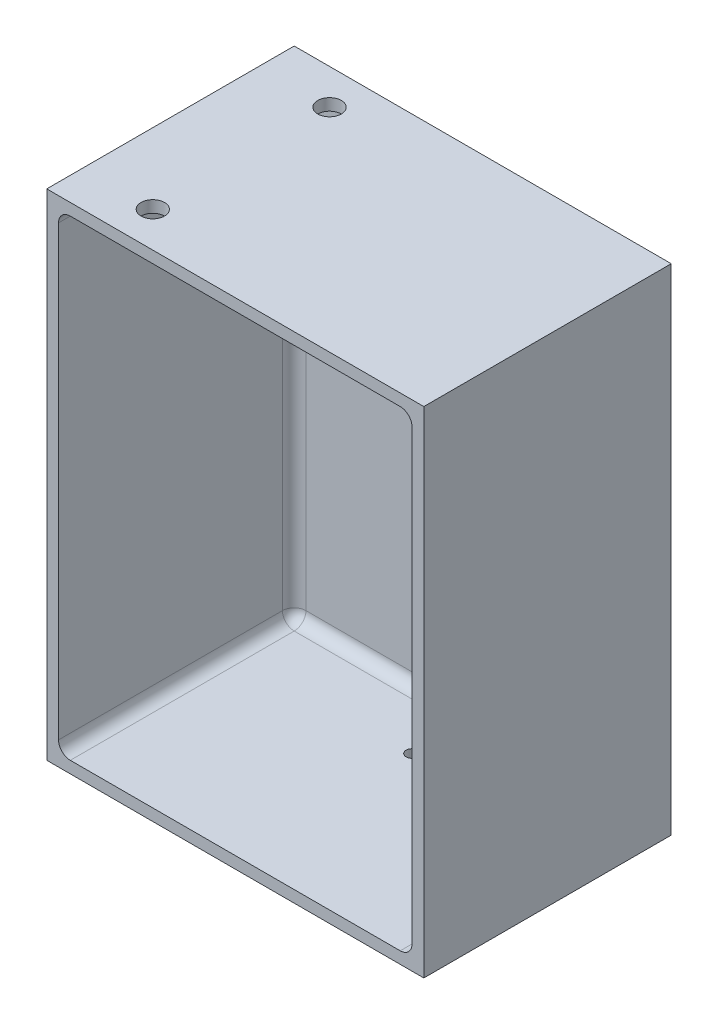
from build123d import *

# Parameters (mm, degrees)
SKETCH1_W           = 160
SKETCH1_H           = 210
SKETCH1_W_2         = 150
SKETCH1_H_2         = 200
BOSS_EXTRUDE1_DEPTH = 100
SKETCH3_W           = 160
SKETCH3_H           = 210
BOSS_EXTRUDE2_DEPTH = 5
FILLET1_R           = 5
SKETCH4_R           = 5
CUT_EXTRUDE1_DEPTH  = 48
SKETCH5_R           = 2.5
CUT_EXTRUDE2_DEPTH  = 40


with BuildPart() as part:
    # Sketch1 → Boss-Extrude1 (new body)
    with BuildSketch(Plane.XY):
        Rectangle(SKETCH1_W, SKETCH1_H)
        Rectangle(SKETCH1_W_2, SKETCH1_H_2, mode=Mode.SUBTRACT)
    extrude(amount=BOSS_EXTRUDE1_DEPTH)

    # Sketch3 → Boss-Extrude2 (add)
    with BuildSketch(Plane(origin=(0, 0, 0), x_dir=(-1, 0, 0), z_dir=(0, 0, -1))):
        Rectangle(SKETCH3_W, SKETCH3_H)
    extrude(amount=BOSS_EXTRUDE2_DEPTH)

    # Fillet1
    fillet1_edges = [part.edges().sort_by_distance(p)[0] for p in [
        (-75, 0, 0),
        (-75, 100, 50),
        (0, -100, 0),
        (-75, -100, 50),
        (75, 0, 0),
        (75, -100, 50),
        (0, 100, 0),
        (75, 100, 50),
    ]]
    fillet(fillet1_edges, radius=FILLET1_R)

    # Sketch4 → Cut-Extrude1 (cut)
    with BuildSketch(Plane(origin=(0, 105, 0), x_dir=(1, 0, 0), z_dir=(0, 1, 0))):
        with Locations((-50, -10)):
            Circle(SKETCH4_R)
        with Locations((-50, -85)):
            Circle(SKETCH4_R)
    extrude(amount=-CUT_EXTRUDE1_DEPTH, mode=Mode.SUBTRACT)

    # Sketch5 → Cut-Extrude2 (cut)
    with BuildSketch(Plane.XZ.offset(105)):
        with Locations((0, 25)):
            Circle(SKETCH5_R)
    extrude(amount=-CUT_EXTRUDE2_DEPTH, mode=Mode.SUBTRACT)


solid = part.part
